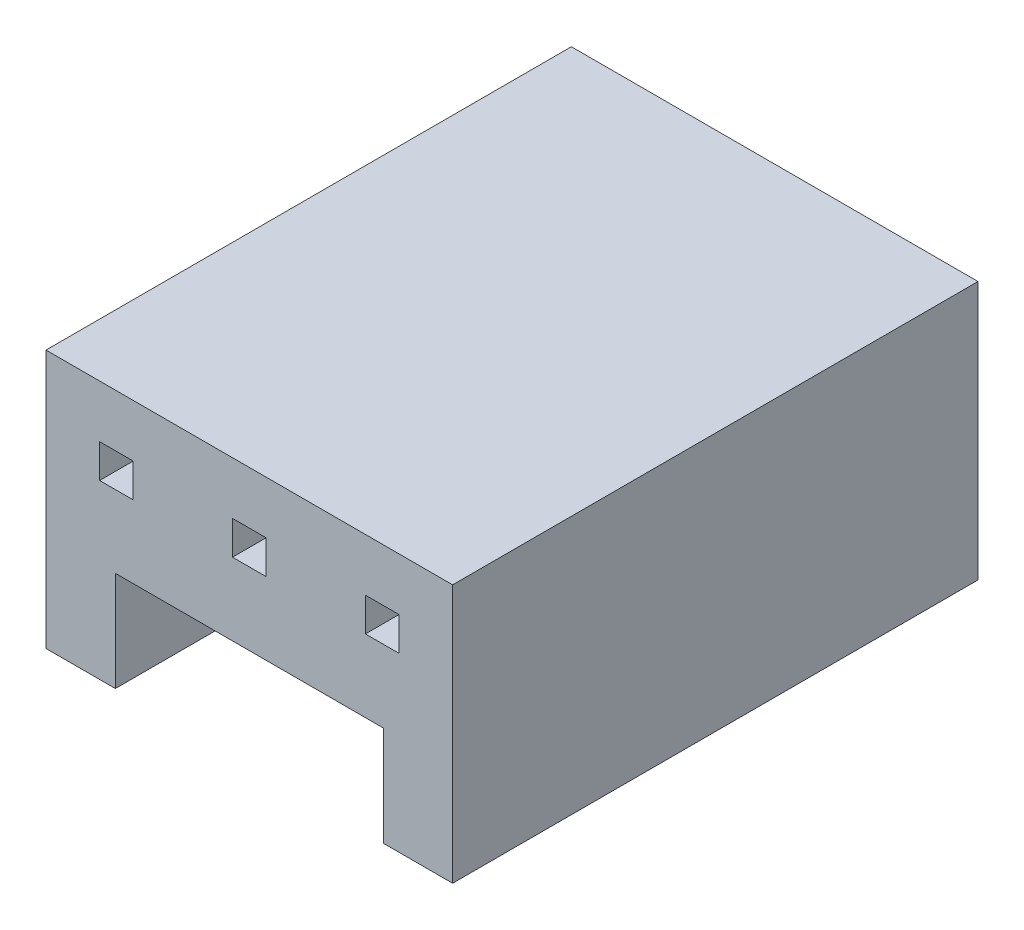
from build123d import *

# Parameters (mm, degrees)
SKETCH1_W           = 7.74
SKETCH1_H           = 4.92
BOSS_EXTRUDE1_DEPTH = 10
SKETCH2_W           = 5.1
SKETCH2_H           = 1.9
CUT_EXTRUDE1_DEPTH  = 11
SKETCH3_W           = 0.32
SKETCH3_H           = 0.64
SKETCH3_W_2         = 0.64
CUT_EXTRUDE2_DEPTH  = 11


with BuildPart() as part:
    # Sketch1 → Boss-Extrude1 (new body)
    with BuildSketch(Plane.XY):
        with Locations((3.87, 2.46)):
            Rectangle(SKETCH1_W, SKETCH1_H)
    extrude(amount=-BOSS_EXTRUDE1_DEPTH)

    # Sketch2 → Cut-Extrude1 (cut, through all)
    with BuildSketch(Plane.XY):
        with Locations((3.87, 0.95)):
            Rectangle(SKETCH2_W, SKETCH2_H)
    extrude(amount=-CUT_EXTRUDE1_DEPTH, mode=Mode.SUBTRACT)

    # Sketch3 → Cut-Extrude2 (cut, through all)
    with BuildSketch(Plane.XY):
        with Locations((3.71, 3.6)):
            Rectangle(SKETCH3_W, SKETCH3_H)
        with Locations((1.34, 3.6)):
            Rectangle(SKETCH3_W_2, SKETCH3_H)
    cut_extrude2 = extrude(amount=-CUT_EXTRUDE2_DEPTH, mode=Mode.SUBTRACT)

    # Mirror1: Cut-Extrude2 across plane
    add(cut_extrude2.mirror(Plane.ZY.offset(-3.87)), mode=Mode.SUBTRACT)


solid = part.part
